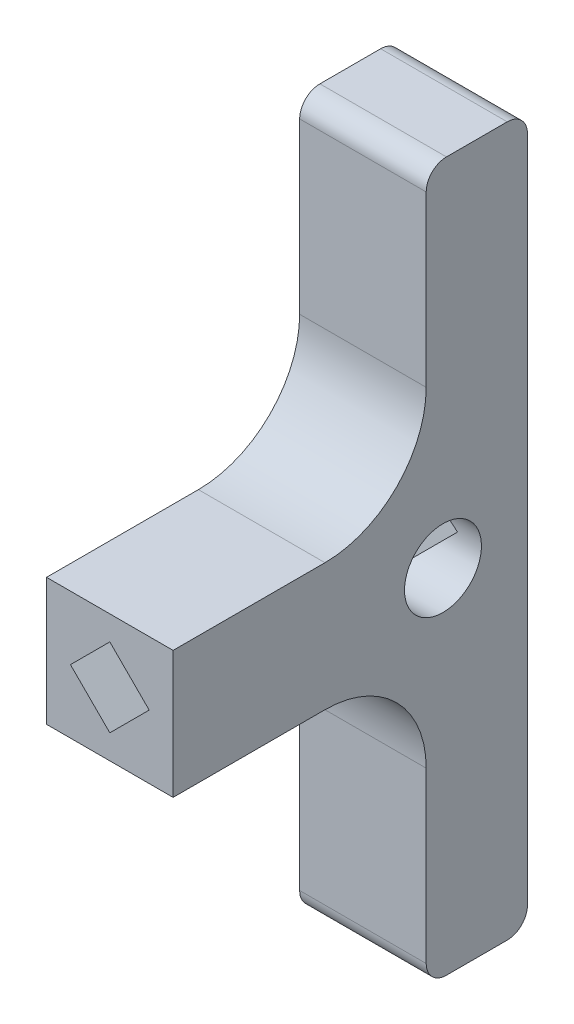
from build123d import *

# Parameters (mm, degrees)
ESQUISSE1_W             = 12.5
ESQUISSE1_H             = 70
BOSS_EXTRU_1_DEPTH      = 10
ESQUISSE2_W             = 12.5
ESQUISSE2_H             = 12.576917286
BOSS_EXTRU_2_DEPTH      = 35
ENL_V_MAT_EXTRU_1_DEPTH = 40
CONG_1_R                = 10
CONG_3_R                = 2
D_GAGEMENT_M71_D        = 7.6
D_GAGEMENT_M71_DEPTH    = 12.5
D_GAGEMENT_M71_TIP      = 2.283270352


with BuildPart() as part:
    # Esquisse1 → Boss.-Extru.1 (new body)
    with BuildSketch(Plane.XY):
        Rectangle(ESQUISSE1_W, ESQUISSE1_H)
    extrude(amount=BOSS_EXTRU_1_DEPTH)

    # Esquisse2 → Boss.-Extru.2 (add)
    with BuildSketch(Plane(origin=(0, 0, 0), x_dir=(-1, 0, 0), z_dir=(0, 0, -1))):
        Rectangle(ESQUISSE2_W, ESQUISSE2_H)
    extrude(amount=-BOSS_EXTRU_2_DEPTH)

    # Esquisse3 → Enlèv. mat.-Extru.1 (cut)
    with BuildSketch(Plane(origin=(0, 0, 0), x_dir=(-1, 0, 0), z_dir=(0, 0, -1))):
        Polygon((-3.889087297, 0), (0, 3.889087297), (3.889087297, 0), (0, -3.889087297), align=None)
    extrude(amount=-ENL_V_MAT_EXTRU_1_DEPTH, mode=Mode.SUBTRACT)

    # Congé1
    cong_1_edges = [part.edges().sort_by_distance(p)[0] for p in [
        (0, -6.288458643, 10),
        (0, 6.288458643, 10),
    ]]
    fillet(cong_1_edges, radius=CONG_1_R)

    # Congé3
    cong_3_edges = [part.edges().sort_by_distance(p)[0] for p in [
        (0, -35, 10),
        (0, -35, 0),
        (0, 35, 0),
        (0, 35, 10),
    ]]
    fillet(cong_3_edges, radius=CONG_3_R)

    # Dégagement M71
    with Locations(Plane.ZY.offset(6.25)):
        with Locations((8.344762473, 0)):
            Hole(D_GAGEMENT_M71_D / 2, depth=D_GAGEMENT_M71_DEPTH)
            with Locations((0, 0, -(D_GAGEMENT_M71_DEPTH + D_GAGEMENT_M71_TIP / 2))):  # 118° drill point
                Cone(0, D_GAGEMENT_M71_D / 2, D_GAGEMENT_M71_TIP, mode=Mode.SUBTRACT)


solid = part.part
